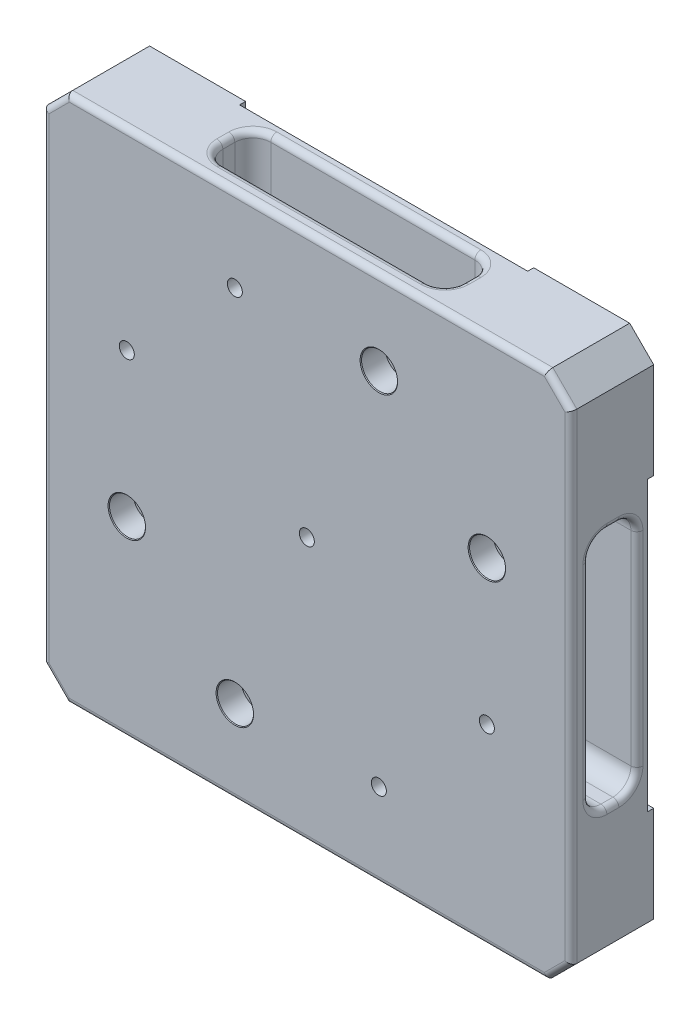
from build123d import *

# Parameters (mm, degrees)
BOSS_EXTRUDE1_DEPTH                           = 40.64
F_3_8_16_TAPPED_HOLE1_D                       = 7.9375
CBORE_FOR_3_8_SOCKET_HEAD_CAP_SCREW1_AT_COUNT = 2
CBORE_FOR_3_8_SOCKET_HEAD_CAP_SCREW1_AT_PITCH = 188.585378542
CBORE_FOR_3_8_SOCKET_HEAD_CAP_SCREW1_2_COUNT  = 2
CBORE_FOR_3_8_SOCKET_HEAD_CAP_SCREW1_2_PITCH  = 80.82230509
CBORE_FOR_3_8_SOCKET_HEAD_CAP_SCREW1_3_COUNT  = 2
CBORE_FOR_3_8_SOCKET_HEAD_CAP_SCREW1_3_PITCH  = 205.174779152
FILLET1_R                                     = 3.175
CUT_EXTRUDE2_DEPTH                            = 28.448
FILLET2_R                                     = 3.175
CIRPATTERN1_COUNT                             = 4
FILLET2_OF_CIRPATTERN1_R                      = 3.175
BOSS_EXTRUDE2_DEPTH                           = 3.175


with BuildPart() as part:
    # Sketch1 → Boss-Extrude1 (new body)
    with BuildSketch(Plane.XY):
        Polygon((-127, 139.7), (127, 139.7), (139.7, 127), (139.7, -127), (127, -139.7), (-127, -139.7), (-139.7, -127), (-139.7, 127), align=None)
    extrude(amount=BOSS_EXTRUDE1_DEPTH)

    # 3_8-16 Tapped Hole1 (through all)
    with Locations(Plane.XY.offset(40.64)):
        with Locations((-95.25, 38.1), (-38.1, 95.25), (38.1, -95.25), (95.25, -38.1), (0, 0)):
            Hole(F_3_8_16_TAPPED_HOLE1_D / 2)

    # Sketch7 → CBORE for 3_8 Socket Head Cap Screw1 (revolve, cut)
    with BuildSketch(Plane(origin=(-95.25, -38.1, 40.64), x_dir=(0, -1, 0), z_dir=(1, 0, 0))):
        Polygon((0, 0), (0, 40.64), (5.8674, 40.64), (5.4483, 40.2209), (5.4483, 12.7), (9.525, 12.7), (9.525, 0.381), (9.906, 0), align=None)
    cbore_for_3_8_socket_head_cap_screw1 = revolve(axis=Axis((-95.25, -38.1, 46.99), (0, 0, -1)), mode=Mode.SUBTRACT)

    # CBORE for 3_8 Socket Head Cap Screw1 at: CBORE for 3_8 Socket Head Cap Screw1 ×2
    with Locations(*[Vector(0.707106781, 0.707106781, 0) * (i * CBORE_FOR_3_8_SOCKET_HEAD_CAP_SCREW1_AT_PITCH) for i in range(1, CBORE_FOR_3_8_SOCKET_HEAD_CAP_SCREW1_AT_COUNT)]):
        add(cbore_for_3_8_socket_head_cap_screw1, mode=Mode.SUBTRACT)

    # CBORE for 3_8 Socket Head Cap Screw1 2: CBORE for 3_8 Socket Head Cap Screw1 ×2
    with Locations(*[Vector(0.707106781, -0.707106781, 0) * (i * CBORE_FOR_3_8_SOCKET_HEAD_CAP_SCREW1_2_PITCH) for i in range(1, CBORE_FOR_3_8_SOCKET_HEAD_CAP_SCREW1_2_COUNT)]):
        add(cbore_for_3_8_socket_head_cap_screw1, mode=Mode.SUBTRACT)

    # CBORE for 3_8 Socket Head Cap Screw1 3: CBORE for 3_8 Socket Head Cap Screw1 ×2
    with Locations(*[Vector(0.928476691, 0.371390676, 0) * (i * CBORE_FOR_3_8_SOCKET_HEAD_CAP_SCREW1_3_PITCH) for i in range(1, CBORE_FOR_3_8_SOCKET_HEAD_CAP_SCREW1_3_COUNT)]):
        add(cbore_for_3_8_socket_head_cap_screw1, mode=Mode.SUBTRACT)

    # Fillet1
    fillet1_edges = [part.edges().sort_by_distance(p)[0] for p in [
        (-133.35, -133.35, 40.64),
        (0, -139.7, 40.64),
        (133.35, -133.35, 40.64),
        (139.7, 0, 40.64),
        (133.35, 133.35, 40.64),
        (0, 139.7, 40.64),
        (-133.35, 133.35, 40.64),
        (-139.7, 0, 40.64),
    ]]
    fillet(fillet1_edges, radius=FILLET1_R)

    # Sketch9 → Cut-Extrude2 (cut)
    with BuildSketch(Plane.XZ.offset(139.7)):
        with BuildLine():
            Line((-53.975, 31.115), (53.975, 31.115))
            ThreePointArc((53.975, 31.115), (60.710192091, 28.325192091), (63.5, 21.59))
            Line((63.5, 21.59), (63.5, 15.24))
            ThreePointArc((63.5, 15.24), (60.710192091, 8.504807909), (53.975, 5.715))
            Line((53.975, 5.715), (-53.975, 5.715))
            ThreePointArc((-53.975, 5.715), (-60.710192091, 8.504807909), (-63.5, 15.24))
            Line((-63.5, 15.24), (-63.5, 21.59))
            ThreePointArc((-63.5, 21.59), (-60.710192091, 28.325192091), (-53.975, 31.115))
        make_face()
    cut_extrude2 = extrude(amount=-CUT_EXTRUDE2_DEPTH, mode=Mode.SUBTRACT)

    # Fillet2
    fillet2_edges = [part.edges().sort_by_distance(p)[0] for p in [
        (60.710192091, -139.7, 28.325192091),
        (0, -139.7, 31.115),
        (-60.710192091, -139.7, 28.325192091),
        (-63.5, -139.7, 18.415),
        (-60.710192091, -139.7, 8.504807909),
        (0, -139.7, 5.715),
        (60.710192091, -139.7, 8.504807909),
        (63.5, -139.7, 18.415),
    ]]
    fillet(fillet2_edges, radius=FILLET2_R)

    # CirPattern1: Cut-Extrude2 ×4 about axis
    cirpattern1_axis = Axis((0, 0, 0), (0, 0, 1))
    for i in range(1, CIRPATTERN1_COUNT):
        add(cut_extrude2.rotate(cirpattern1_axis, i * 360 / CIRPATTERN1_COUNT), mode=Mode.SUBTRACT)

    # Fillet2 of CirPattern1
    fillet2_of_cirpattern1_edges = [part.edges().sort_by_distance(p)[0] for p in [
        (139.7, 60.710192091, 28.325192091),
        (139.7, 0, 31.115),
        (139.7, -60.710192091, 28.325192091),
        (139.7, -63.5, 18.415),
        (139.7, -60.710192091, 8.504807909),
        (139.7, 0, 5.715),
        (139.7, 60.710192091, 8.504807909),
        (139.7, 63.5, 18.415),
        (-60.710192091, 139.7, 28.325192091),
        (0, 139.7, 31.115),
        (60.710192091, 139.7, 28.325192091),
        (63.5, 139.7, 18.415),
        (60.710192091, 139.7, 8.504807909),
        (0, 139.7, 5.715),
        (-60.710192091, 139.7, 8.504807909),
        (-63.5, 139.7, 18.415),
        (-139.7, -60.710192091, 28.325192091),
        (-139.7, 0, 31.115),
        (-139.7, 60.710192091, 28.325192091),
        (-139.7, 63.5, 18.415),
        (-139.7, 60.710192091, 8.504807909),
        (-139.7, 0, 5.715),
        (-139.7, -60.710192091, 8.504807909),
        (-139.7, -63.5, 18.415),
    ]]
    fillet(fillet2_of_cirpattern1_edges, radius=FILLET2_OF_CIRPATTERN1_R)

    # Sketch2 → Boss-Extrude2 (add)
    with BuildSketch(Plane(origin=(0, 0, 0), x_dir=(-1, 0, 0), z_dir=(0, 0, -1))):
        Polygon((127, -139.7), (76.2, -139.7), (76.2, -76.2), (139.7, -76.2), (139.7, -127), align=None)
        Polygon((-76.2, -139.7), (-127, -139.7), (-139.7, -127), (-139.7, -76.2), (-76.2, -76.2), align=None)
        Polygon((139.7, 76.2), (76.2, 76.2), (76.2, 139.7), (127, 139.7), (139.7, 127), align=None)
        Polygon((-127, 139.7), (-76.2, 139.7), (-76.2, 76.2), (-139.7, 76.2), (-139.7, 127), align=None)
    extrude(amount=BOSS_EXTRUDE2_DEPTH)


solid = part.part
